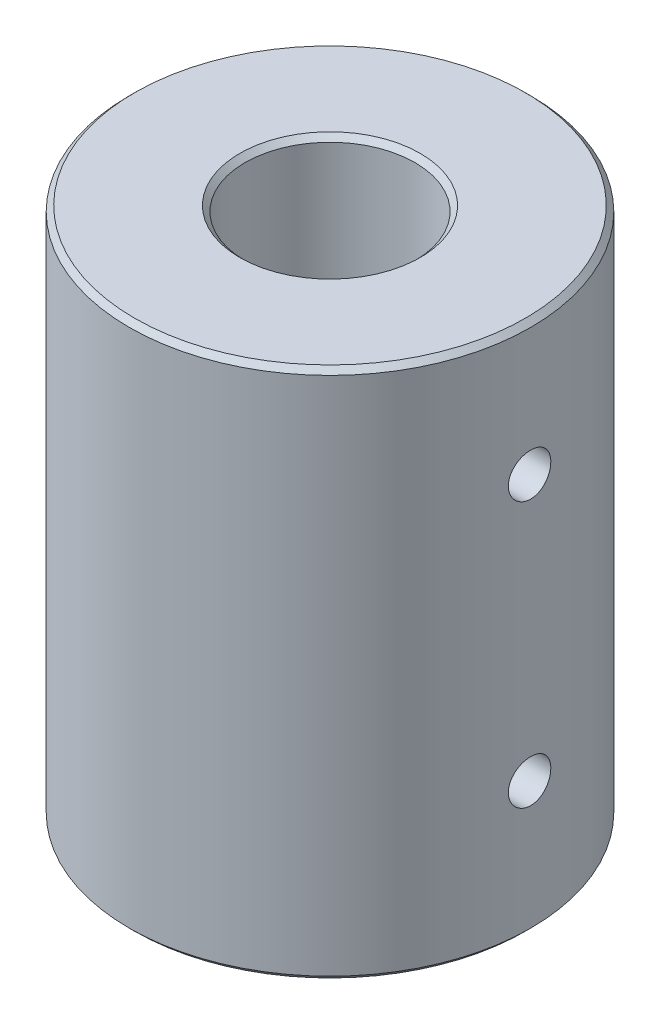
from build123d import *

# Parameters (mm, degrees)
SKETCH1_R           = 9.45
SKETCH1_R_2         = 4
BOSS_EXTRUDE1_DEPTH = 25
SKETCH2_R           = 1
CUT_EXTRUDE1_DEPTH  = 12.5
CHAMFER1_SIZE       = 0.25


with BuildPart() as part:
    # Sketch1 → Boss-Extrude1 (new body)
    with BuildSketch(Plane(origin=(0, 0, 0), x_dir=(1, 0, 0), z_dir=(0, 1, 0))):
        Circle(SKETCH1_R)
        Circle(SKETCH1_R_2, mode=Mode.SUBTRACT)
    extrude(amount=BOSS_EXTRUDE1_DEPTH)

    # Sketch2 → Cut-Extrude1 (cut, symmetric)
    with BuildSketch(Plane(origin=(0, 0, 0), x_dir=(0, 0, -1), z_dir=(1, 0, 0))):
        with Locations((0, 6.25)):
            Circle(SKETCH2_R)
        with Locations((0, 18.75)):
            Circle(SKETCH2_R)
    extrude(amount=CUT_EXTRUDE1_DEPTH, both=True, mode=Mode.SUBTRACT)

    # Chamfer1
    chamfer1_edges = [part.edges().sort_by_distance(p)[0] for p in [
        (-9.45, 0, 0),
        (-9.45, 25, 0),
        (-4, 0, 0),
        (-4, 25, 0),
    ]]
    chamfer(chamfer1_edges, length=CHAMFER1_SIZE)


solid = part.part
